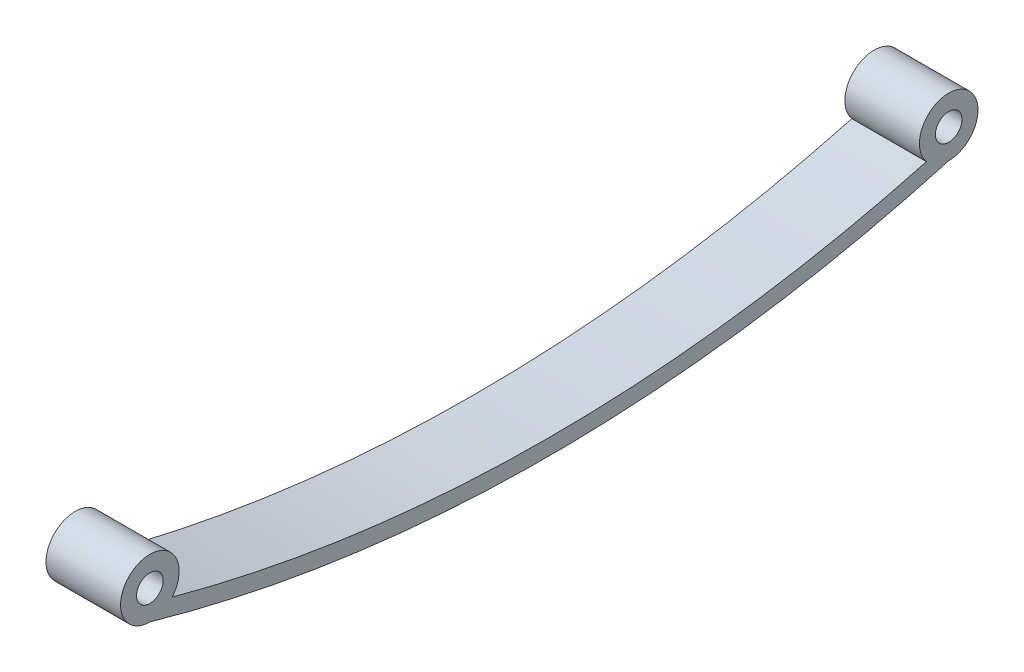
from build123d import *

# Parameters (mm, degrees)
SKETCH1_R           = 1.25
BOSS_EXTRUDE1_DEPTH = 7


with BuildPart() as part:
    # Sketch1 → Boss-Extrude1 (new body)
    with BuildSketch(Plane(origin=(0, 0, 0), x_dir=(0, 0, -1), z_dir=(1, 0, 0))):
        with BuildLine():
            ThreePointArc((-35.401670986, -1.77750256), (-38.656366715, 2.49505832), (-37.5, -2.75))
            ThreePointArc((-37.5, -2.75), (0, -8), (37.5, -2.75))
            ThreePointArc((37.5, -2.75), (38.656366715, 2.49505832), (35.401670986, -1.77750256))
            ThreePointArc((35.401670986, -1.77750256), (0, -6.5), (-35.401670986, -1.77750256))
        make_face()
        with Locations((-37.5, 0)):
            Circle(SKETCH1_R, mode=Mode.SUBTRACT)
        with Locations((37.5, 0)):
            Circle(SKETCH1_R, mode=Mode.SUBTRACT)
    extrude(amount=BOSS_EXTRUDE1_DEPTH)


solid = part.part
